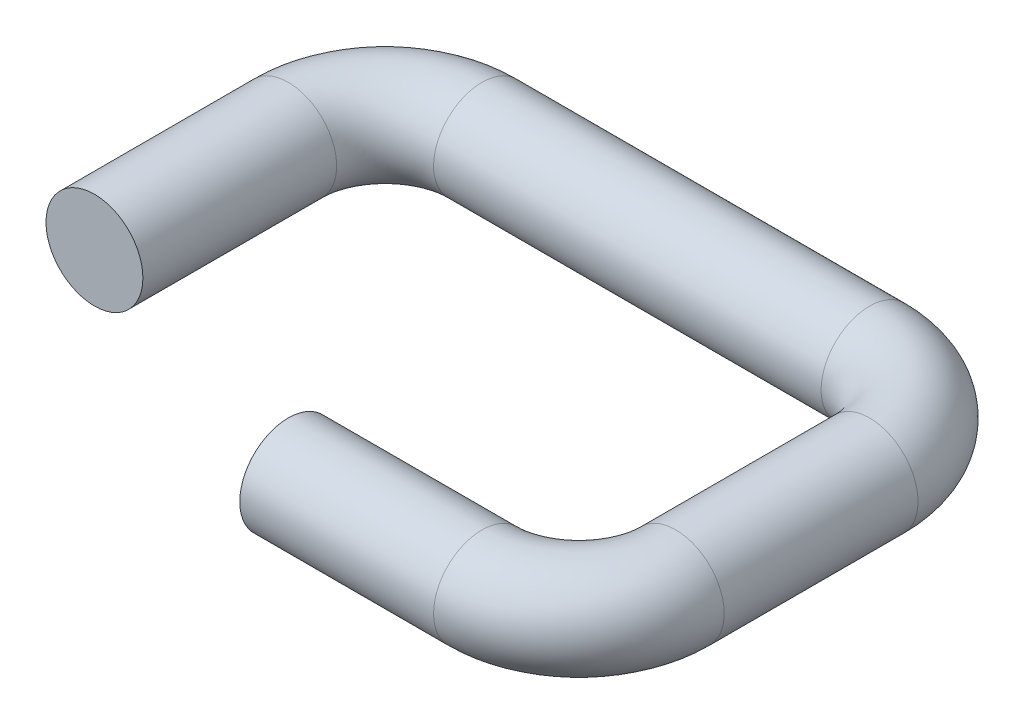
from build123d import *

# Parameters (mm, degrees)
SWEEP1_PROFILE_R = 2.5


with BuildPart() as part:
    # Sweep1: sweep along a path in Sketch1
    with BuildLine(Plane(origin=(0, 0, 0), x_dir=(1, 0, 0), z_dir=(0, 1, 0))) as sweep1_path:
        Line((0, 0), (0, 10))
        ThreePointArc((0, 10), (1.464466094, 13.535533906), (5, 15))
        Line((5, 15), (25, 15))
        ThreePointArc((25, 15), (28.535533906, 13.535533906), (30, 10))
        Line((30, 10), (30, 0))
        ThreePointArc((30, 0), (28.535533906, -3.535533906), (25, -5))
        Line((25, -5), (15, -5))
    # Sweep1 profile (on start of the path) → Sweep1 (sweep)
    with BuildSketch(Plane(origin=(0, 0, 0), x_dir=(-1, 0, 0), z_dir=(0, 0, -1))):
        Circle(SWEEP1_PROFILE_R)
    sweep(path=sweep1_path.line)


solid = part.part
